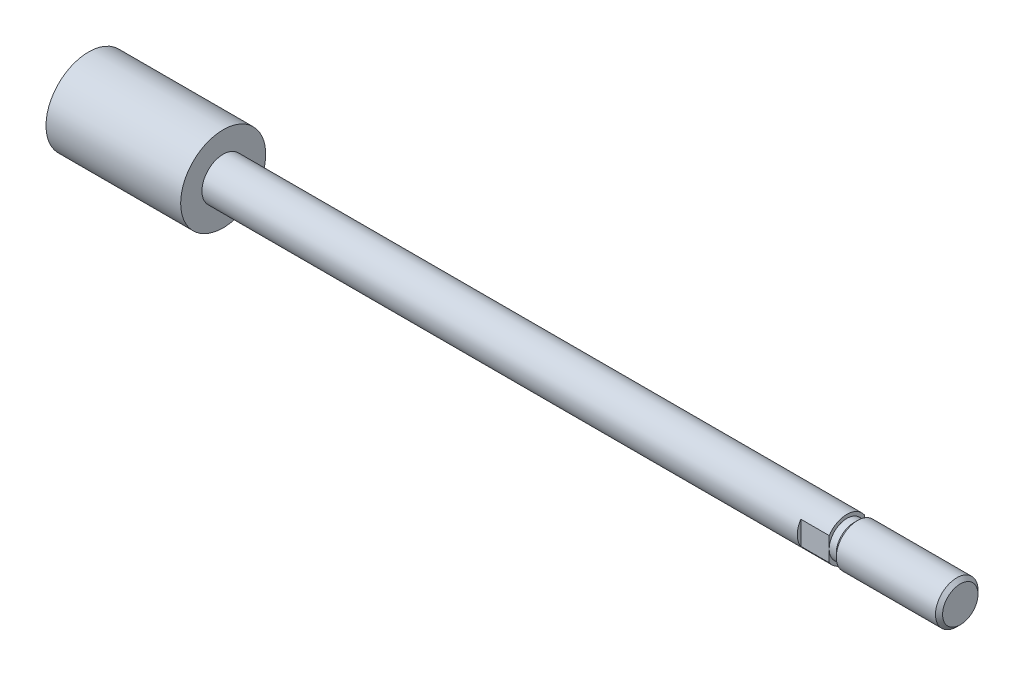
from build123d import *

# Parameters (mm, degrees)
CHAMFER1_SIZE      = 0.5
SKETCH2_W          = 3.5
SKETCH2_H          = 12
CUT_EXTRUDE1_DEPTH = 4


with BuildPart() as part:
    # Sketch1 → Revolve1 (revolve)
    with BuildSketch(Plane.XY):
        Polygon((0, -6), (0, 0), (123, 0), (123, -3), (108.5, -3), (108, -2.5), (107, -2.5), (107, -3), (19, -3), (19, -6), align=None)
    revolve(axis=Axis((-26.391164048, 0, 0), (1, 0, 0)))

    # Chamfer1
    chamfer1_edges = [part.edges().sort_by_distance(p)[0] for p in [
        (123, 3, 0),
    ]]
    chamfer(chamfer1_edges, length=CHAMFER1_SIZE)

    # Sketch2 → Cut-Extrude1 (cut)
    with BuildSketch(Plane(origin=(107, 0, 0), x_dir=(0, 0, -1), z_dir=(1, 0, 0))):
        with Locations((-4.25, 0)):
            Rectangle(SKETCH2_W, SKETCH2_H)
    cut_extrude1 = extrude(amount=-CUT_EXTRUDE1_DEPTH, mode=Mode.SUBTRACT)

    # Mirror1: Cut-Extrude1 across plane
    add(cut_extrude1.mirror(Plane.XY), mode=Mode.SUBTRACT)


solid = part.part
